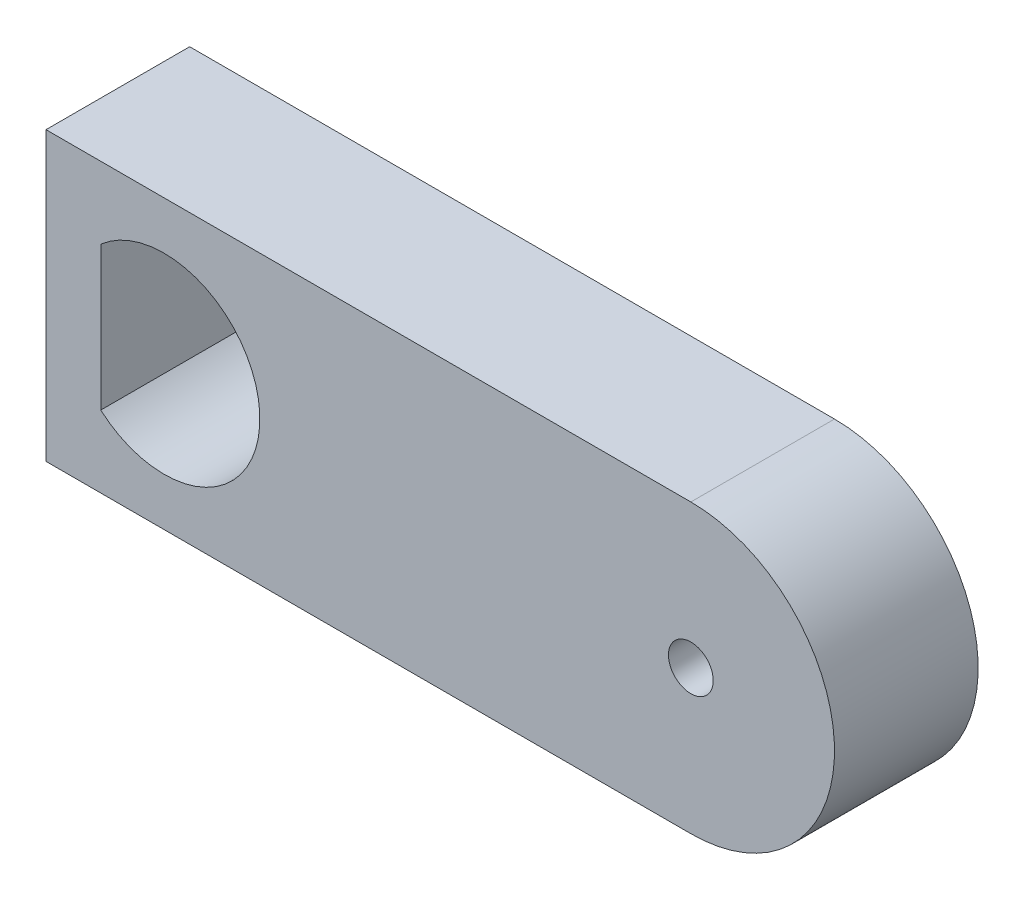
from build123d import *

# Parameters (mm, degrees)
SKETCH1_R           = 0.467713673
BOSS_EXTRUDE1_DEPTH = 3


with BuildPart() as part:
    # Sketch1 → Boss-Extrude1 (new body)
    with BuildSketch(Plane.XY):
        with BuildLine():
            Line((-7.145342709, -3), (6.320992929, -3))
            ThreePointArc((6.320992929, -3), (9.320992929, 0), (6.320992929, 3))
            Line((6.320992929, 3), (-7.145342709, 3))
            Line((-7.145342709, 3), (-7.145342709, -3))
        make_face()
        with Locations((6.320992929, 0)):
            Circle(SKETCH1_R, mode=Mode.SUBTRACT)
        with BuildLine():
            Line((-6.001882726, 1.5), (-6.001882726, -1.5))
            ThreePointArc((-6.001882726, -1.5), (-2.679007071, 0), (-6.001882726, 1.5))
        make_face(mode=Mode.SUBTRACT)
    extrude(amount=BOSS_EXTRUDE1_DEPTH)


solid = part.part
